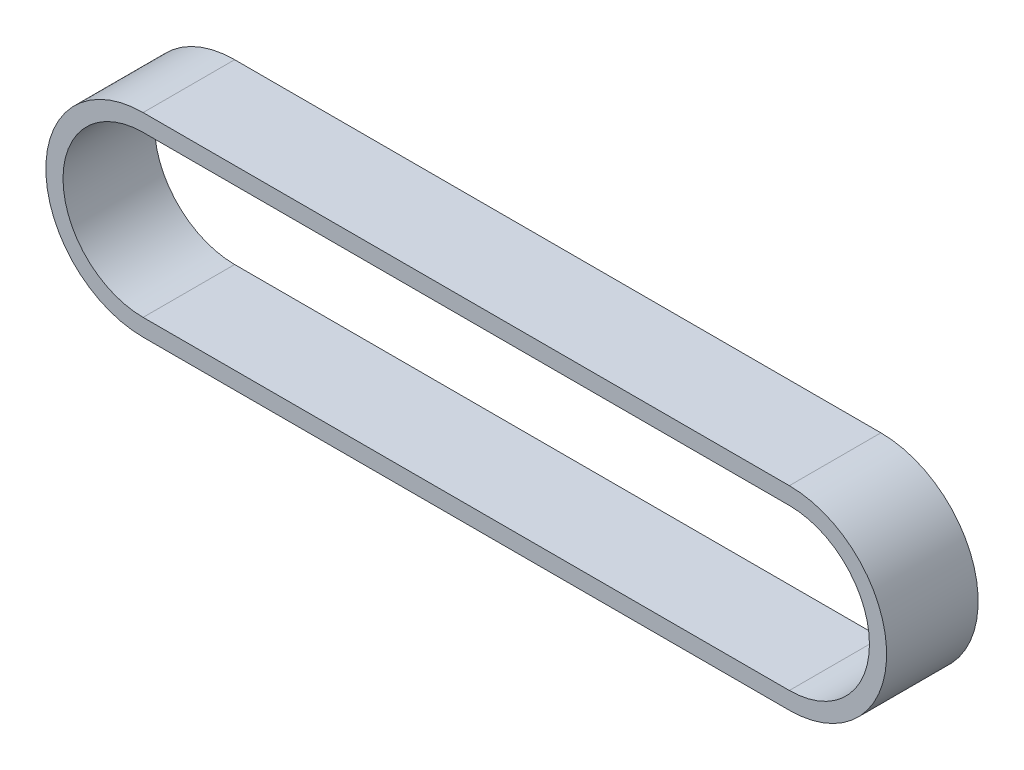
from build123d import *

# Parameters (mm, degrees)
ESTRUSIONE_ESTRUSIONE2_DEPTH = 6.4


with BuildPart() as part:
    # Schizzo1 → Estrusione-Estrusione2 (new body)
    with BuildSketch(Plane.XY):
        with BuildLine():
            Line((0, 6.8), (-45.177427992, 6.8))
            ThreePointArc((-45.177427992, 6.8), (-51.977427992, 0), (-45.177427992, -6.8))
            Line((-45.177427992, -6.8), (0, -6.8))
            ThreePointArc((0, -6.8), (6.8, 0), (0, 6.8))
        make_face()
        with BuildLine():
            ThreePointArc((-45.177427992, 5.6), (-50.777427992, 0), (-45.177427992, -5.6))
            Line((-45.177427992, -5.6), (0, -5.6))
            ThreePointArc((0, -5.6), (5.6, 0), (0, 5.6))
            Line((0, 5.6), (-45.177427992, 5.6))
        make_face(mode=Mode.SUBTRACT)
    extrude(amount=ESTRUSIONE_ESTRUSIONE2_DEPTH)


solid = part.part
